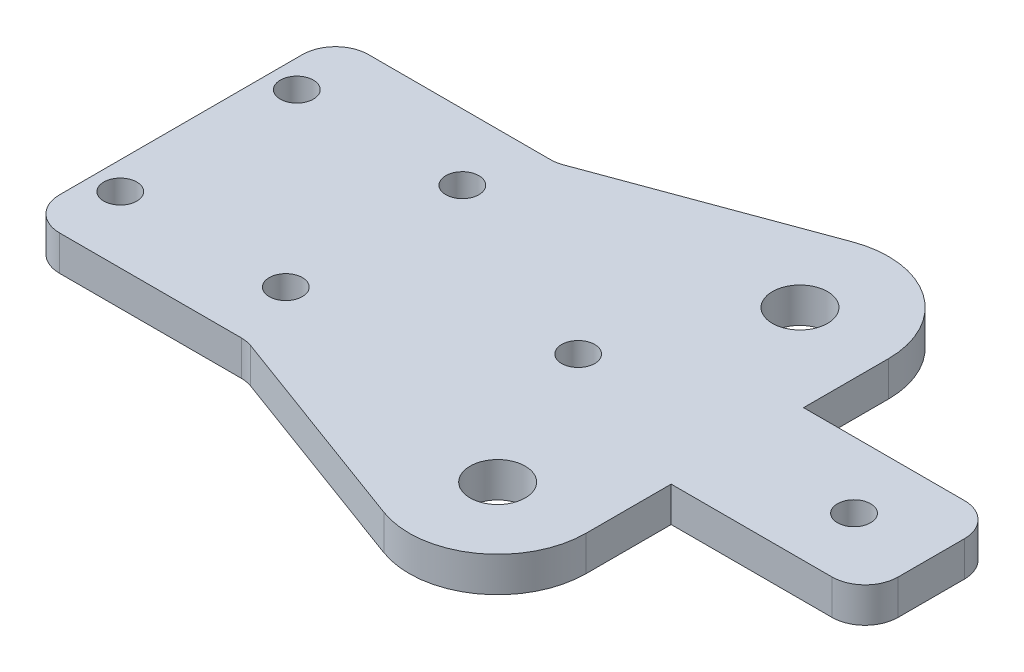
from build123d import *

# Parameters (mm, degrees)
SKETCH1_R           = 1.5
SKETCH1_R_2         = 2.5
BOSS_EXTRUDE1_DEPTH = 3.175
FILLET1_R           = 3


with BuildPart() as part:
    # Sketch1 → Boss-Extrude1 (new body)
    with BuildSketch(Plane(origin=(0, 0, 0), x_dir=(1, 0, 0), z_dir=(0, 1, 0))):
        with BuildLine():
            Line((0, -14), (0, 14))
            Line((0, 14), (20, 14))
            Line((20, 14), (39.625823576, 21.230243699))
            ThreePointArc((39.625823576, 21.230243699), (46.990090369, 20.282681475), (50.425, 13.7))
            Line((50.425, 13.7), (50.425, 6))
            Line((50.425, 6), (68, 6))
            Line((68, 6), (68, -6))
            Line((68, -6), (50.425, -6))
            Line((50.425, -6), (50.425, -13.7))
            ThreePointArc((50.425, -13.7), (46.990090369, -20.282681475), (39.625823576, -21.230243699))
            Line((39.625823576, -21.230243699), (20, -14))
            Line((20, -14), (0, -14))
        make_face()
        with Locations((2.5, 8)):
            Circle(SKETCH1_R, mode=Mode.SUBTRACT)
        with Locations((17.5, 8)):
            Circle(SKETCH1_R, mode=Mode.SUBTRACT)
        with Locations((17.5, -8)):
            Circle(SKETCH1_R, mode=Mode.SUBTRACT)
        with Locations((2.5, -8)):
            Circle(SKETCH1_R, mode=Mode.SUBTRACT)
        with Locations((42.4, 13.7)):
            Circle(SKETCH1_R_2, mode=Mode.SUBTRACT)
        with Locations((42.4, -13.7)):
            Circle(SKETCH1_R_2, mode=Mode.SUBTRACT)
        with Locations((36, 0)):
            Circle(SKETCH1_R, mode=Mode.SUBTRACT)
        with Locations((61, 0)):
            Circle(SKETCH1_R, mode=Mode.SUBTRACT)
    extrude(amount=BOSS_EXTRUDE1_DEPTH)

    # Fillet1
    fillet1_edges = [part.edges().sort_by_distance(p)[0] for p in [
        (0, 1.5875, 14),
        (0, 1.5875, -14),
        (20, 1.5875, -14),
        (68, 1.5875, -6),
        (68, 1.5875, 6),
        (20, 1.5875, 14),
    ]]
    fillet(fillet1_edges, radius=FILLET1_R)


solid = part.part
